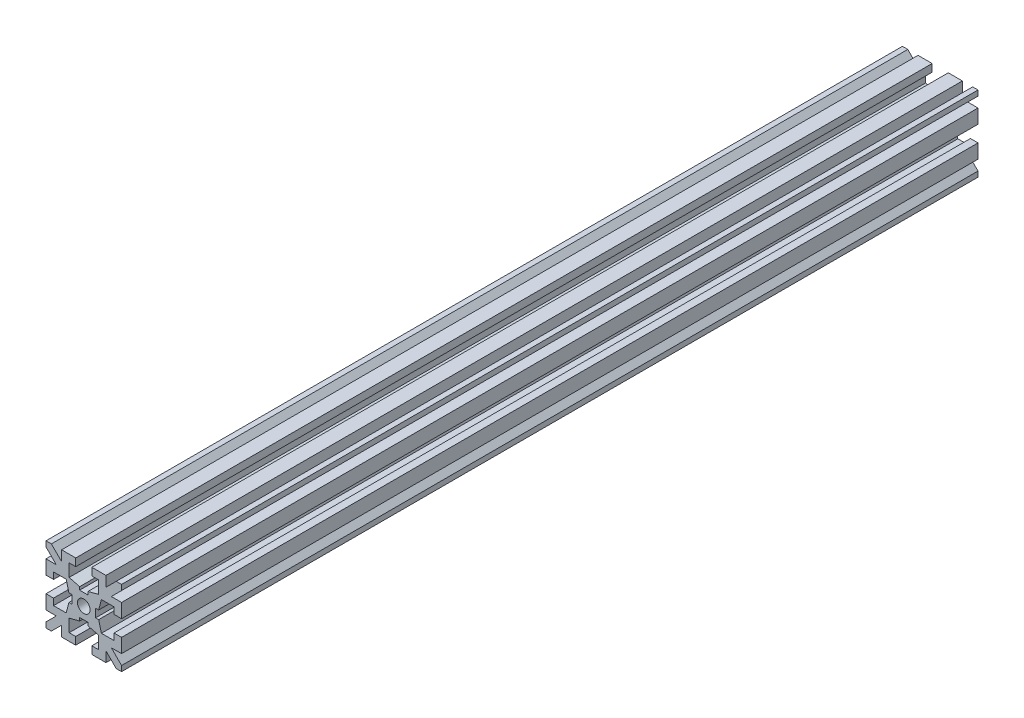
from build123d import *

# Parameters (mm, degrees)
RESSALTO_EXTRUS_O1_DEPTH   = 85
ESPELHAR2_COPY_1_DEPTH     = 85
ESBO_O2_R                  = 1.25
CORTE_EXTRUS_O1_DEPTH      = 1
CORTE_EXTRUS_O1_DEPTH_BACK = 171


with BuildPart() as part:
    # Esboço1 → Ressalto-extrusão1 (new body, symmetric)
    with BuildSketch(Plane.XY):
        Polygon((0, 2.35), (-0.825, 2.35), (-0.825, 2.95), (-2.9, 3.5), (-2.9, 6), (-1.6, 6), (-1.6, 7.5), (-4.4, 7.5), (-4.4, 5.460660172), (-6.439339828, 7.5), (-7.5, 7.5), (-7.5, 6.439339828), (-5.460660172, 4.4), (-7.5, 4.4), (-7.5, 1.6), (-6, 1.6), (-6, 2.9), (-3.5, 2.9), (-2.95, 0.825), (-2.35, 0.825), (-2.35, 0), (0, 0), align=None)
    ressalto_extrus_o1 = extrude(amount=RESSALTO_EXTRUS_O1_DEPTH, both=True)

    # Espelhar1: Ressalto-extrusão1 across plane
    add(ressalto_extrus_o1.mirror(Plane.ZX))

    # Espelhar2: Ressalto-extrusão1 across plane
    add(ressalto_extrus_o1.mirror(Plane(origin=(0, 0, 0), x_dir=(0, 0, 1), z_dir=(1, 0, 0))))

    # Espelhar2 copy 1 sketch → Espelhar2 copy 1 (add, symmetric)
    with BuildSketch(Plane(origin=(0, 0, 0), x_dir=(-1, 0, 0), z_dir=(0, 0, 1))):
        Polygon((0, 2.35), (-0.825, 2.35), (-0.825, 2.95), (-2.9, 3.5), (-2.9, 6), (-1.6, 6), (-1.6, 7.5), (-4.4, 7.5), (-4.4, 5.460660172), (-6.439339828, 7.5), (-7.5, 7.5), (-7.5, 6.439339828), (-5.460660172, 4.4), (-7.5, 4.4), (-7.5, 1.6), (-6, 1.6), (-6, 2.9), (-3.5, 2.9), (-2.95, 0.825), (-2.35, 0.825), (-2.35, 0), (0, 0), align=None)
    extrude(amount=ESPELHAR2_COPY_1_DEPTH, both=True)

    # Esboço2 → Corte-extrusão1 (cut, two sides)
    with BuildSketch(Plane.XY.offset(85)) as corte_extrus_o1_sk:
        Circle(ESBO_O2_R)
    extrude(amount=CORTE_EXTRUS_O1_DEPTH, mode=Mode.SUBTRACT)
    extrude(corte_extrus_o1_sk.sketch, amount=-CORTE_EXTRUS_O1_DEPTH_BACK, mode=Mode.SUBTRACT)


solid = part.part
